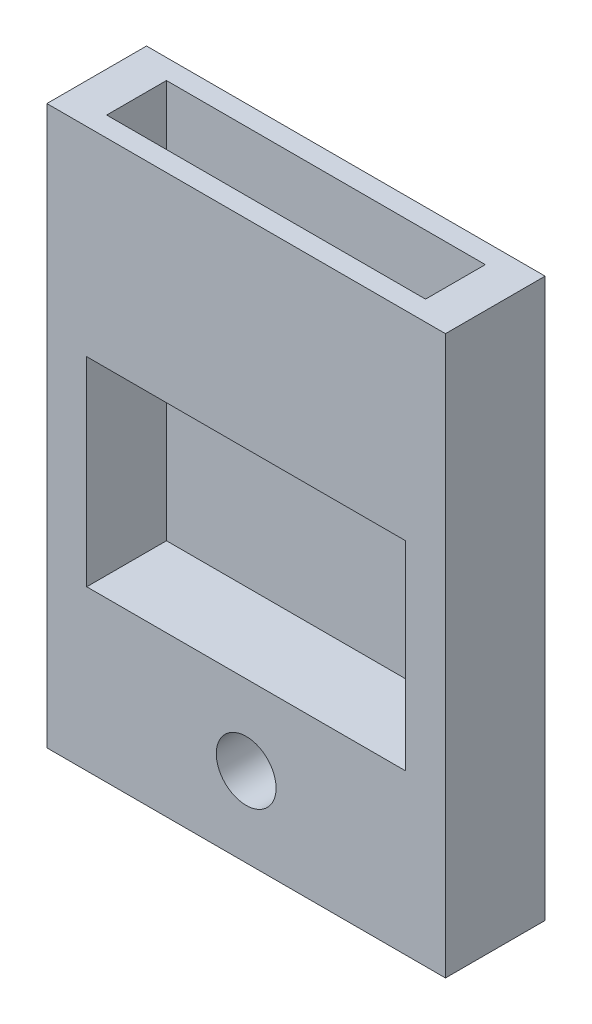
from build123d import *

# Parameters (mm, degrees)
SKETCH1_W           = 20
SKETCH1_H           = 28
BOSS_EXTRUDE1_DEPTH = 5
SKETCH2_R           = 1.5
CUT_EXTRUDE1_DEPTH  = 5
SKETCH3_W           = 16
SKETCH3_H           = 3
CUT_EXTRUDE2_DEPTH  = 20
SKETCH4_W           = 16
SKETCH4_H           = 10
CUT_EXTRUDE3_DEPTH  = 4


with BuildPart() as part:
    # Sketch1 → Boss-Extrude1 (new body)
    with BuildSketch(Plane.XY):
        with Locations((10, 14)):
            Rectangle(SKETCH1_W, SKETCH1_H)
    extrude(amount=BOSS_EXTRUDE1_DEPTH)

    # Sketch2 → Cut-Extrude1 (cut)
    with BuildSketch(Plane.XY.offset(5)):
        with Locations((10, 4)):
            Circle(SKETCH2_R)
    extrude(amount=-CUT_EXTRUDE1_DEPTH, mode=Mode.SUBTRACT)

    # Sketch3 → Cut-Extrude2 (cut)
    with BuildSketch(Plane(origin=(0, 28, 0), x_dir=(1, 0, 0), z_dir=(0, 1, 0))):
        with Locations((10, -2.5)):
            Rectangle(SKETCH3_W, SKETCH3_H)
    extrude(amount=-CUT_EXTRUDE2_DEPTH, mode=Mode.SUBTRACT)

    # Sketch4 → Cut-Extrude3 (cut)
    with BuildSketch(Plane.XY.offset(5)):
        with Locations((10, 13)):
            Rectangle(SKETCH4_W, SKETCH4_H)
    extrude(amount=-CUT_EXTRUDE3_DEPTH, mode=Mode.SUBTRACT)


solid = part.part
